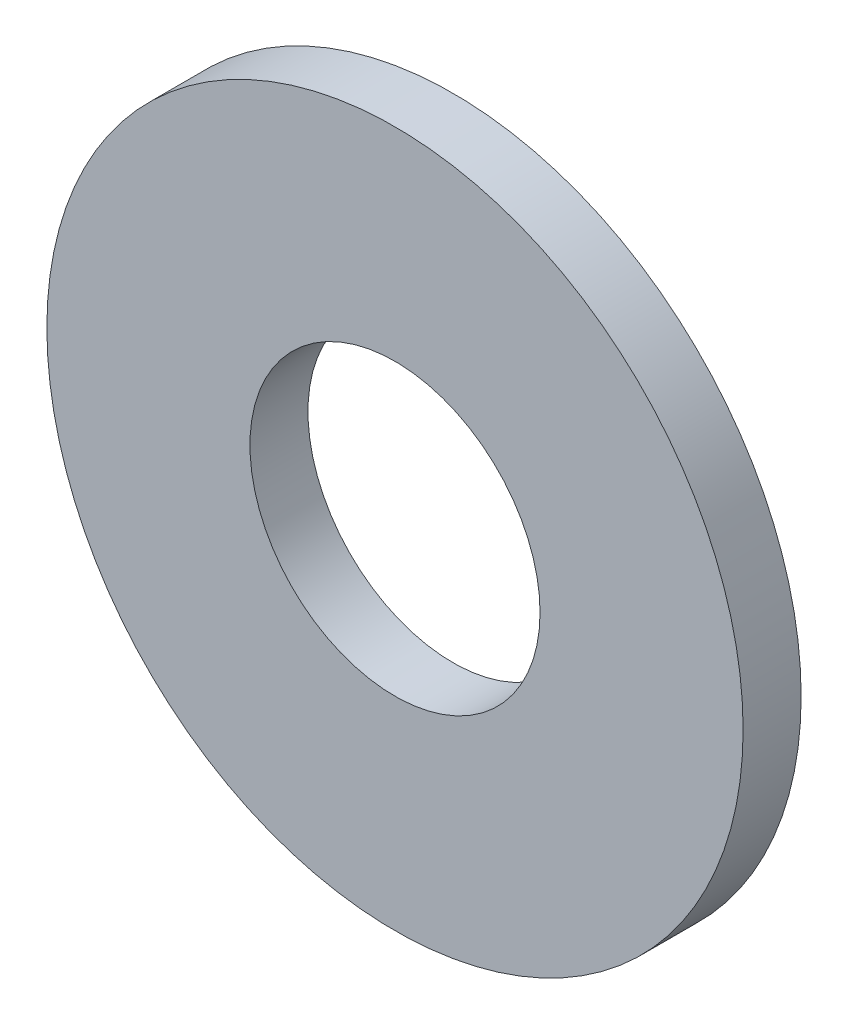
from build123d import *

# Parameters (mm, degrees)
SKETCH_1_R      = 6
SKETCH_1_R_2    = 2.5
EXTRUDE_1_DEPTH = 1


with BuildPart() as part:
    # Эскиз1 → Бобышка-Вытянуть1 (new body)
    with BuildSketch(Plane.XY):
        Circle(SKETCH_1_R)
        Circle(SKETCH_1_R_2, mode=Mode.SUBTRACT)
    extrude(amount=EXTRUDE_1_DEPTH)


solid = part.part
